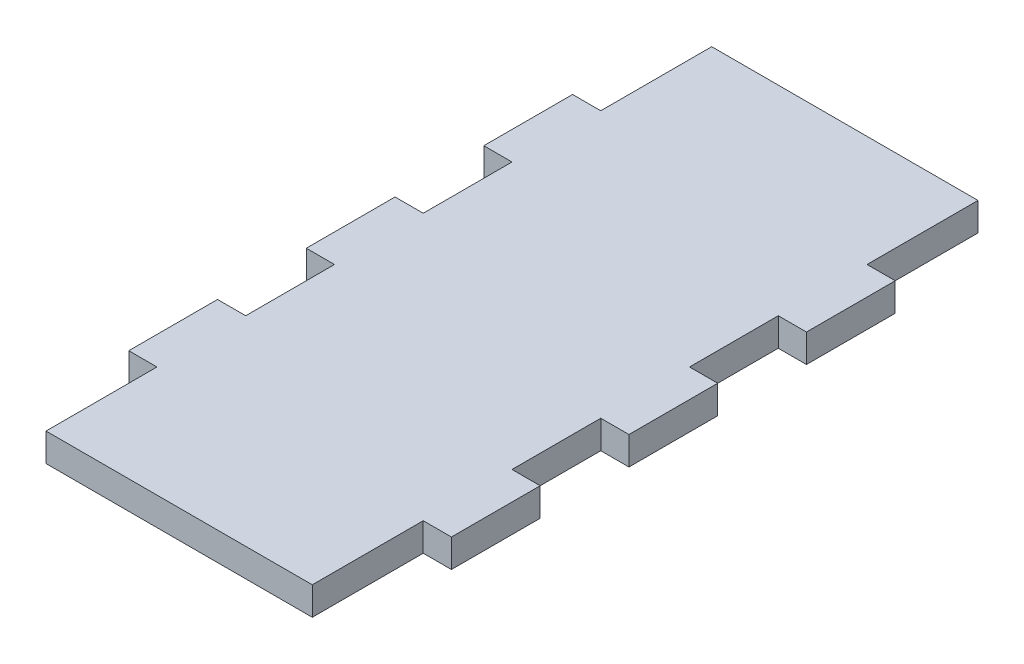
from build123d import *

# Parameters (mm, degrees)
SKETCH1_W           = 30
SKETCH1_H           = 75
BOSS_EXTRUDE1_DEPTH = 3.175
SKETCH2_W           = 3.175
SKETCH2_H           = 10
BOSS_EXTRUDE2_DEPTH = 3.175


with BuildPart() as part:
    # Sketch1 → Boss-Extrude1 (new body)
    with BuildSketch(Plane(origin=(0, 0, 0), x_dir=(1, 0, 0), z_dir=(0, 1, 0))):
        Rectangle(SKETCH1_W, SKETCH1_H)
    extrude(amount=BOSS_EXTRUDE1_DEPTH)

    # Sketch2 → Boss-Extrude2 (add)
    with BuildSketch(Plane(origin=(0, 3.175, 0), x_dir=(1, 0, 0), z_dir=(0, 1, 0))):
        with Locations((-16.5875, 0)):
            Rectangle(SKETCH2_W, SKETCH2_H)
        with Locations((-16.5875, -20)):
            Rectangle(SKETCH2_W, SKETCH2_H)
        with Locations((-16.5875, 20)):
            Rectangle(SKETCH2_W, SKETCH2_H)
        with Locations((16.5875, -20)):
            Rectangle(SKETCH2_W, SKETCH2_H)
        with Locations((16.5875, 0)):
            Rectangle(SKETCH2_W, SKETCH2_H)
        with Locations((16.5875, 20)):
            Rectangle(SKETCH2_W, SKETCH2_H)
    extrude(amount=-BOSS_EXTRUDE2_DEPTH)


solid = part.part
